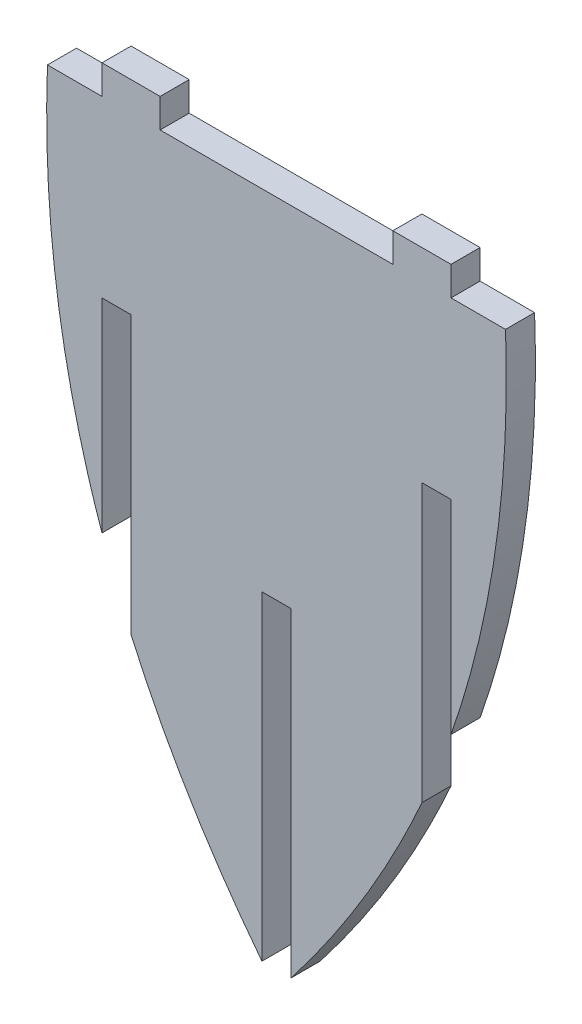
from build123d import *

# Parameters (mm, degrees)
BOSS_EXTRUDE1_DEPTH = 6.35


with BuildPart() as part:
    # Sketch1 → Boss-Extrude1 (new body)
    with BuildSketch(Plane.XY):
        with BuildLine():
            Line((-53.175, 406.4), (-41.275, 406.4))
            Line((-41.275, 406.4), (-41.275, 412.75))
            Line((-41.275, 412.75), (-28.575, 412.75))
            Line((-28.575, 412.75), (-28.575, 406.4))
            Line((-28.575, 406.4), (-6.35, 406.4))
            Line((-6.35, 406.4), (22.225, 406.4))
            Line((22.225, 406.4), (22.225, 412.75))
            Line((22.225, 412.75), (34.925, 412.75))
            Line((34.925, 412.75), (34.925, 406.4))
            Line((34.925, 406.4), (46.825, 406.4))
            add(Edge.make_bspline(
                [(46.825, 406.4), (48.444514788, 362.591265004), (34.925, 323.85)],
                knots=[0, 0, 0, 0.535068669, 0.535068669, 0.535068669], degree=2))
            Line((34.925, 323.85), (34.925, 368.3))
            Line((34.925, 368.3), (28.575, 368.3))
            Line((28.575, 368.3), (28.575, 307.792730185))
            add(Edge.make_bspline(
                [(28.575, 307.792730185), (17.572742264, 282.971699721), (0, 260.35)],
                knots=[0.647499935, 0.647499935, 0.647499935, 1, 1, 1], degree=2))
            Line((0, 260.35), (0, 330.2))
            Line((0, 330.2), (-6.35, 330.2))
            Line((-6.35, 330.2), (-6.35, 260.35))
            add(Edge.make_bspline(
                [(-34.925, 307.792730185), (-23.922742264, 282.971699721), (-6.35, 260.35)],
                knots=[0.647499935, 0.647499935, 0.647499935, 1, 1, 1], degree=2))
            Line((-34.925, 307.792730185), (-34.925, 368.3))
            Line((-34.925, 368.3), (-41.275, 368.3))
            Line((-41.275, 368.3), (-41.275, 323.85))
            add(Edge.make_bspline(
                [(-53.175, 406.4), (-54.794514788, 362.591265004), (-41.275, 323.85)],
                knots=[0, 0, 0, 0.535068669, 0.535068669, 0.535068669], degree=2))
        make_face()
    extrude(amount=BOSS_EXTRUDE1_DEPTH)


solid = part.part
